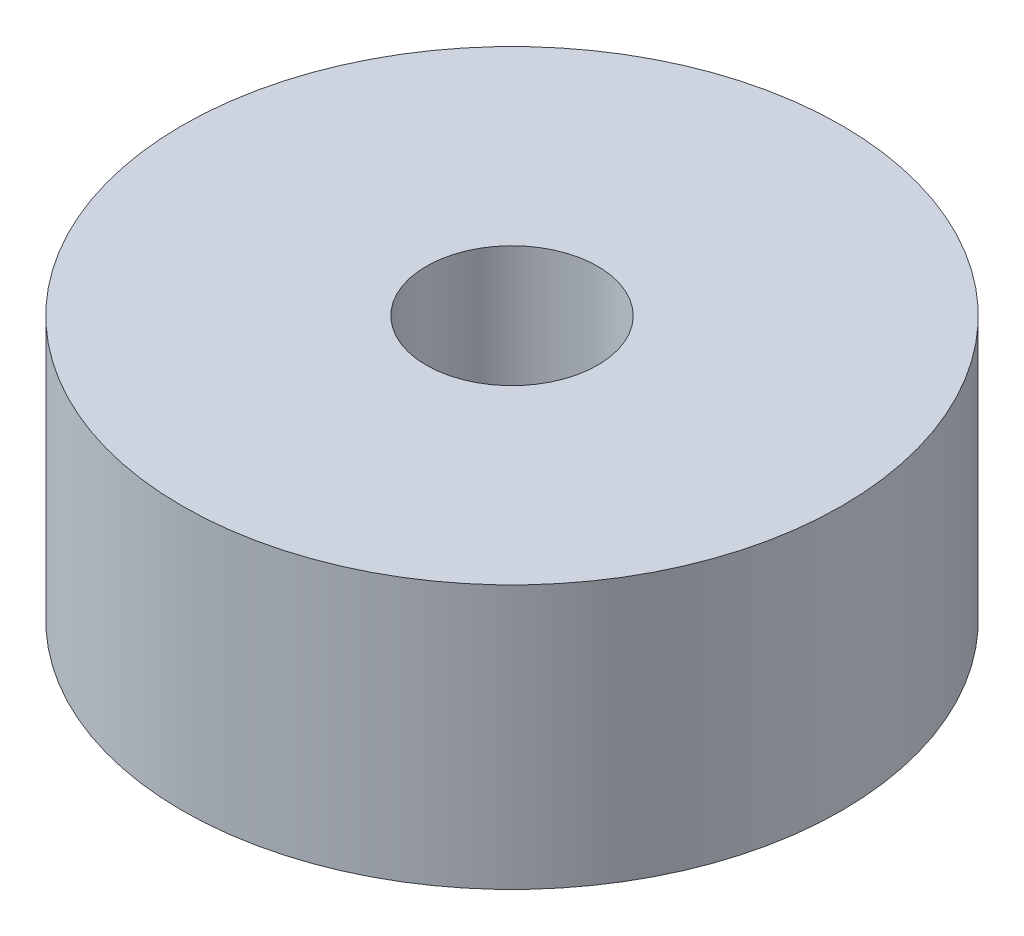
from build123d import *

# Parameters (mm, degrees)
SKETCH1_R           = 12.5
BOSS_EXTRUDE1_DEPTH = 10
SKETCH3_R           = 3.25
CUT_EXTRUDE2_DEPTH  = 11


with BuildPart() as part:
    # Sketch1 → Boss-Extrude1 (new body)
    with BuildSketch(Plane(origin=(0, 0, 0), x_dir=(1, 0, 0), z_dir=(0, 1, 0))):
        Circle(SKETCH1_R)
    extrude(amount=BOSS_EXTRUDE1_DEPTH)

    # Sketch3 → Cut-Extrude2 (cut, through all)
    with BuildSketch(Plane(origin=(0, 10, 0), x_dir=(1, 0, 0), z_dir=(0, 1, 0))):
        Circle(SKETCH3_R)
    extrude(amount=-CUT_EXTRUDE2_DEPTH, mode=Mode.SUBTRACT)


solid = part.part
